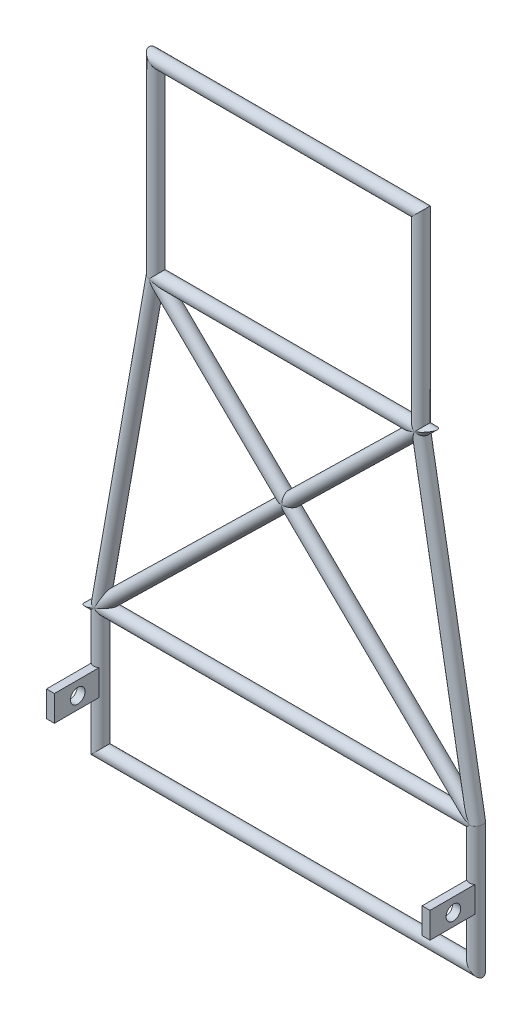
from build123d import *

# Parameters (mm, degrees)
SKETCH11_R                              = 10.65
SKETCH11_R_2                            = 8.35
PIPE_CONFIGURED_21_3_X_2_3_1_DEPTH      = 316.061374439
PIPE_CONFIGURED_21_3_X_2_3_1_DEPTH_BACK = 2.317699521
SKETCH11_ON_SEGMENT_2_R                 = 10.65
SKETCH11_ON_SEGMENT_2_R_2               = 8.35
PIPE_CONFIGURED_21_3_X_2_3_1_2_DEPTH    = 455.79576817
SKETCH11_ON_SEGMENT_3_R                 = 10.65
SKETCH11_ON_SEGMENT_3_R_2               = 8.35
PIPE_CONFIGURED_21_3_X_2_3_1_3_DEPTH    = 318.37907396
SKETCH11_ON_SEGMENT_4_R                 = 10.65
SKETCH11_ON_SEGMENT_4_R_2               = 8.35
PIPE_CONFIGURED_21_3_X_2_3_1_4_DEPTH    = 512.348704984
SKETCH11_ON_SEGMENT_5_R                 = 10.65
SKETCH11_ON_SEGMENT_5_R_2               = 8.35
PIPE_CONFIGURED_21_3_X_2_3_1_5_DEPTH    = 218.37907396
SKETCH11_ON_SEGMENT_6_R                 = 10.65
SKETCH11_ON_SEGMENT_6_R_2               = 8.35
PIPE_CONFIGURED_21_3_X_2_3_1_6_DEPTH    = 632.122748879
SKETCH11_ON_SEGMENT_7_R                 = 10.65
SKETCH11_ON_SEGMENT_7_R_2               = 8.35
PIPE_CONFIGURED_21_3_X_2_3_1_7_DEPTH    = 218.37907396
SKETCH11_ON_SEGMENT_8_R                 = 10.65
SKETCH11_ON_SEGMENT_8_R_2               = 8.35
PIPE_CONFIGURED_21_3_X_2_3_1_8_DEPTH    = 512.348704984
SKETCH12_R                              = 10.65
SKETCH12_R_2                            = 8.35
PIPE_CONFIGURED_21_3_X_2_3_2_DEPTH      = 461.644534185
SKETCH12_ON_SEGMENT_2_R                 = 10.65
SKETCH12_ON_SEGMENT_2_R_2               = 8.35
PIPE_CONFIGURED_21_3_X_2_3_2_2_DEPTH    = 791.468439963
SKETCH12_ON_SEGMENT_3_R                 = 10.65
SKETCH12_ON_SEGMENT_3_R_2               = 8.35
PIPE_CONFIGURED_21_3_X_2_3_2_3_DEPTH    = 637.971514894
SKETCH13_R                              = 10.65
SKETCH13_R_2                            = 8.35
PIPE_CONFIGURED_21_3_X_2_3_3_DEPTH      = 715.525410175
SKETCH14_W                              = 12.640078246
SKETCH14_H                              = 41.290922271
BOSS_EXTRUDE1_DEPTH                     = 80
BOSS_EXTRUDE1_2_DEPTH                   = 80
SKETCH16_R                              = 11.698728684
CUT_EXTRUDE1_DEPTH                      = 730


with BuildPart() as part:
    # Sketch11 → Pipe - configured 21.3 X 2.3(1) (new, two sides)
    with BuildSketch(Plane(origin=(-211.836509646, 700, 0), x_dir=(-1, 0, 0), z_dir=(0, 1, 0))) as pipe_configured_21_3_x_2_3_1_sk:
        Circle(SKETCH11_R)
        Circle(SKETCH11_R_2, mode=Mode.SUBTRACT)
    extrude(amount=PIPE_CONFIGURED_21_3_X_2_3_1_DEPTH)
    extrude(pipe_configured_21_3_x_2_3_1_sk.sketch, amount=-PIPE_CONFIGURED_21_3_X_2_3_1_DEPTH_BACK)

    # Pipe - configured 21.3 X 2.3(1) mitre 1
    split(bisect_by=Plane(origin=(-211.836509646, 700, 0), x_dir=(-0.996194698, 0.087155743, 0), z_dir=(0.087155743, 0.996194698, 0)), keep=Keep.TOP)

    # Pipe - configured 21.3 X 2.3(1) mitre 2
    split(bisect_by=Plane(origin=(-211.836509646, 1000, 0), x_dir=(0.707106781, -0.707106781, 0), z_dir=(-0.707106781, -0.707106781, 0)), keep=Keep.TOP)


with BuildPart() as body_2:
    # Sketch11 on segment 2 (carried to segment 2) → Pipe - configured 21.3 X 2.3_1 2 (new body)
    with BuildSketch(Plane(origin=(-227.897884085, 1000, 0), x_dir=(0, 1, 0), z_dir=(1, 0, 0))):
        Circle(SKETCH11_ON_SEGMENT_2_R)
        Circle(SKETCH11_ON_SEGMENT_2_R_2, mode=Mode.SUBTRACT)
    extrude(amount=PIPE_CONFIGURED_21_3_X_2_3_1_2_DEPTH)

    # Pipe - configured 21.3 X 2.3_1 2 mitre 1
    split(bisect_by=Plane(origin=(211.836509646, 1000, 0), x_dir=(-0.707106781, -0.707106781, 0), z_dir=(-0.707106781, 0.707106781, 0)), keep=Keep.TOP)

    # Pipe - configured 21.3 X 2.3_1 2 mitre 2
    split(bisect_by=Plane(origin=(-211.836509646, 1000, 0), x_dir=(-0.707106781, 0.707106781, 0), z_dir=(0.707106781, 0.707106781, 0)), keep=Keep.TOP)


with BuildPart() as body_3:
    # Sketch11 on segment 3 (carried to segment 3) → Pipe - configured 21.3 X 2.3_1 3 (new body)
    with BuildSketch(Plane(origin=(211.836509646, 1016.061374439, 0), x_dir=(1, 0, 0), z_dir=(0, -1, 0))):
        Circle(SKETCH11_ON_SEGMENT_3_R)
        Circle(SKETCH11_ON_SEGMENT_3_R_2, mode=Mode.SUBTRACT)
    extrude(amount=PIPE_CONFIGURED_21_3_X_2_3_1_3_DEPTH)

    # Pipe - configured 21.3 X 2.3_1 3 mitre 1
    split(bisect_by=Plane(origin=(211.836509646, 700, 0), x_dir=(-0.996194698, -0.087155743, 0), z_dir=(-0.087155743, 0.996194698, 0)), keep=Keep.TOP)

    # Pipe - configured 21.3 X 2.3_1 3 mitre 2
    split(bisect_by=Plane(origin=(211.836509646, 1000, 0), x_dir=(0.707106781, 0.707106781, 0), z_dir=(0.707106781, -0.707106781, 0)), keep=Keep.TOP)


with BuildPart() as body_4:
    # Sketch11 on segment 4 (carried to segment 4) → Pipe - configured 21.3 X 2.3_1 4 (new body)
    with BuildSketch(Plane(origin=(211.434045348, 702.282488457, 0), x_dir=(0.984807753, 0.173648178, 0), z_dir=(0.173648178, -0.984807753, 0))):
        Circle(SKETCH11_ON_SEGMENT_4_R)
        Circle(SKETCH11_ON_SEGMENT_4_R_2, mode=Mode.SUBTRACT)
    extrude(amount=PIPE_CONFIGURED_21_3_X_2_3_1_4_DEPTH)

    # Pipe - configured 21.3 X 2.3_1 4 mitre 1
    split(bisect_by=Plane(origin=(300, 200, 0), x_dir=(-0.996194698, -0.087155743, 0), z_dir=(-0.087155743, 0.996194698, 0)), keep=Keep.TOP)

    # Pipe - configured 21.3 X 2.3_1 4 mitre 2
    split(bisect_by=Plane(origin=(211.836509646, 700, 0), x_dir=(0.996194698, 0.087155743, 0), z_dir=(0.087155743, -0.996194698, 0)), keep=Keep.TOP)


with BuildPart() as body_5:
    # Sketch11 on segment 5 (carried to segment 5) → Pipe - configured 21.3 X 2.3_1 5 (new body)
    with BuildSketch(Plane(origin=(300, 202.317699521, 0), x_dir=(1, 0, 0), z_dir=(0, -1, 0))):
        Circle(SKETCH11_ON_SEGMENT_5_R)
        Circle(SKETCH11_ON_SEGMENT_5_R_2, mode=Mode.SUBTRACT)
    extrude(amount=PIPE_CONFIGURED_21_3_X_2_3_1_5_DEPTH)

    # Pipe - configured 21.3 X 2.3_1 5 mitre 1
    split(bisect_by=Plane(origin=(300, 0, 0), x_dir=(-0.707106781, 0.707106781, 0), z_dir=(0.707106781, 0.707106781, 0)), keep=Keep.TOP)

    # Pipe - configured 21.3 X 2.3_1 5 mitre 2
    split(bisect_by=Plane(origin=(300, 200, 0), x_dir=(0.996194698, 0.087155743, 0), z_dir=(0.087155743, -0.996194698, 0)), keep=Keep.TOP)


with BuildPart() as body_6:
    # Sketch11 on segment 6 (carried to segment 6) → Pipe - configured 21.3 X 2.3_1 6 (new body)
    with BuildSketch(Plane(origin=(316.061374439, 0, 0), x_dir=(0, -1, 0), z_dir=(-1, 0, 0))):
        Circle(SKETCH11_ON_SEGMENT_6_R)
        Circle(SKETCH11_ON_SEGMENT_6_R_2, mode=Mode.SUBTRACT)
    extrude(amount=PIPE_CONFIGURED_21_3_X_2_3_1_6_DEPTH)

    # Pipe - configured 21.3 X 2.3_1 6 mitre 1
    split(bisect_by=Plane(origin=(-300, 0, 0), x_dir=(0.707106781, 0.707106781, 0), z_dir=(0.707106781, -0.707106781, 0)), keep=Keep.TOP)

    # Pipe - configured 21.3 X 2.3_1 6 mitre 2
    split(bisect_by=Plane(origin=(300, 0, 0), x_dir=(0.707106781, -0.707106781, 0), z_dir=(-0.707106781, -0.707106781, 0)), keep=Keep.TOP)


with BuildPart() as body_7:
    # Sketch11 on segment 7 (carried to segment 7) → Pipe - configured 21.3 X 2.3_1 7 (new body)
    with BuildSketch(Plane(origin=(-300, -16.061374439, 0), x_dir=(-1, 0, 0), z_dir=(0, 1, 0))):
        Circle(SKETCH11_ON_SEGMENT_7_R)
        Circle(SKETCH11_ON_SEGMENT_7_R_2, mode=Mode.SUBTRACT)
    extrude(amount=PIPE_CONFIGURED_21_3_X_2_3_1_7_DEPTH)

    # Pipe - configured 21.3 X 2.3_1 7 mitre 1
    split(bisect_by=Plane(origin=(-300, 0, 0), x_dir=(-0.707106781, -0.707106781, 0), z_dir=(-0.707106781, 0.707106781, 0)), keep=Keep.TOP)

    # Pipe - configured 21.3 X 2.3_1 7 mitre 2
    split(bisect_by=Plane(origin=(-300, 200, 0), x_dir=(0.996194698, -0.087155743, 0), z_dir=(-0.087155743, -0.996194698, 0)), keep=Keep.TOP)


with BuildPart() as body_8:
    # Sketch11 on segment 8 (carried to segment 8) → Pipe - configured 21.3 X 2.3_1 8 (new body)
    with BuildSketch(Plane(origin=(-300.402464298, 197.717511543, 0), x_dir=(-0.984807753, 0.173648178, 0), z_dir=(0.173648178, 0.984807753, 0))):
        Circle(SKETCH11_ON_SEGMENT_8_R)
        Circle(SKETCH11_ON_SEGMENT_8_R_2, mode=Mode.SUBTRACT)
    extrude(amount=PIPE_CONFIGURED_21_3_X_2_3_1_8_DEPTH)

    # Pipe - configured 21.3 X 2.3_1 8 mitre 1
    split(bisect_by=Plane(origin=(-300, 200, 0), x_dir=(-0.996194698, 0.087155743, 0), z_dir=(0.087155743, 0.996194698, 0)), keep=Keep.TOP)

    # Pipe - configured 21.3 X 2.3_1 8 mitre 2
    split(bisect_by=Plane(origin=(-211.836509646, 700, 0), x_dir=(0.996194698, -0.087155743, 0), z_dir=(-0.087155743, -0.996194698, 0)), keep=Keep.TOP)


with BuildPart() as body_9:
    # Sketch12 → Pipe - configured 21.3 X 2.3(2) (new body)
    with BuildSketch(Plane(origin=(-211.836509646, 700, 0), x_dir=(0, 1, 0), z_dir=(1, 0, 0))):
        Circle(SKETCH12_R)
        Circle(SKETCH12_R_2, mode=Mode.SUBTRACT)
    extrude(amount=PIPE_CONFIGURED_21_3_X_2_3_2_DEPTH)

    # Pipe - configured 21.3 X 2.3(2) mitre 1
    split(bisect_by=Plane(origin=(211.836509646, 700, 0), x_dir=(-0.92610194, -0.377273372, 0), z_dir=(-0.377273372, 0.92610194, 0)), keep=Keep.TOP)


with BuildPart() as body_10:
    # Sketch12 on segment 2 (carried to segment 2) → Pipe - configured 21.3 X 2.3_2 2 (new body)
    with BuildSketch(Plane(origin=(238.998658429, 726.534008684, 0), x_dir=(0.698787203, -0.715329606, 0), z_dir=(-0.715329606, -0.698787203, 0))):
        Circle(SKETCH12_ON_SEGMENT_2_R)
        Circle(SKETCH12_ON_SEGMENT_2_R_2, mode=Mode.SUBTRACT)
    extrude(amount=PIPE_CONFIGURED_21_3_X_2_3_2_2_DEPTH)

    # Pipe - configured 21.3 X 2.3_2 2 mitre 1
    split(bisect_by=Plane(origin=(-300, 200, 0), x_dir=(-0.92610194, -0.377273372, 0), z_dir=(-0.377273372, 0.92610194, 0)), keep=Keep.TOP)

    # Pipe - configured 21.3 X 2.3_2 2 mitre 2
    split(bisect_by=Plane(origin=(211.836509646, 700, 0), x_dir=(0.92610194, 0.377273372, 0), z_dir=(0.377273372, -0.92610194, 0)), keep=Keep.TOP)


with BuildPart() as body_11:
    # Sketch12 on segment 3 (carried to segment 3) → Pipe - configured 21.3 X 2.3_2 3 (new body)
    with BuildSketch(Plane(origin=(-337.971514894, 200, 0), x_dir=(0, 1, 0), z_dir=(1, 0, 0))):
        Circle(SKETCH12_ON_SEGMENT_3_R)
        Circle(SKETCH12_ON_SEGMENT_3_R_2, mode=Mode.SUBTRACT)
    extrude(amount=PIPE_CONFIGURED_21_3_X_2_3_2_3_DEPTH)

    # Pipe - configured 21.3 X 2.3_2 3 mitre 1
    split(bisect_by=Plane(origin=(-300, 200, 0), x_dir=(0.92610194, 0.377273372, 0), z_dir=(0.377273372, -0.92610194, 0)), keep=Keep.TOP)


with BuildPart() as body_12:
    # Sketch13 → Pipe - configured 21.3 X 2.3(3) (new body)
    with BuildSketch(Plane(origin=(300, 200, 0), x_dir=(-0.6987872029276858, -0.7153296058632701, 0), z_dir=(-0.7153296058632701, 0.6987872029276858, 0))):
        Circle(SKETCH13_R)
        Circle(SKETCH13_R_2, mode=Mode.SUBTRACT)
    extrude(amount=PIPE_CONFIGURED_21_3_X_2_3_3_DEPTH)


with BuildPart() as body_13:
    # Sketch14 → Boss-Extrude1 (new body)
    with BuildSketch(Plane.XY):
        with Locations((300.067070693, 99.29785707)):
            Rectangle(SKETCH14_W, SKETCH14_H)
    extrude(amount=BOSS_EXTRUDE1_DEPTH)


with BuildPart() as body_14:
    # Sketch14 → Boss-Extrude1 2 (new body)
    with BuildSketch(Plane.XY):
        with Locations((-300.067070693, 99.29785707)):
            Rectangle(SKETCH14_W, SKETCH14_H)
    extrude(amount=BOSS_EXTRUDE1_2_DEPTH)


with BuildPart() as cut_extrude1_tool:
    # Sketch16 → Cut-Extrude1 (new body)
    with BuildSketch(Plane.ZY.offset(306.387109816)):
        with Locations((42.679791903, 98.195050739)):
            Circle(SKETCH16_R)
    extrude(amount=-CUT_EXTRUDE1_DEPTH)


with BuildPart() as body_13_1:
    add(body_13.part)

    # Cut-Extrude1: cut by cut_extrude1_tool
    add(cut_extrude1_tool.part, mode=Mode.SUBTRACT)


with BuildPart() as body_14_1:
    add(body_14.part)

    # Cut-Extrude1: cut by cut_extrude1_tool
    add(cut_extrude1_tool.part, mode=Mode.SUBTRACT)


solid = Compound([part.part, body_2.part, body_3.part, body_4.part, body_5.part, body_6.part, body_7.part, body_8.part, body_9.part, body_10.part, body_11.part, body_12.part, body_13_1.part, body_14_1.part])
